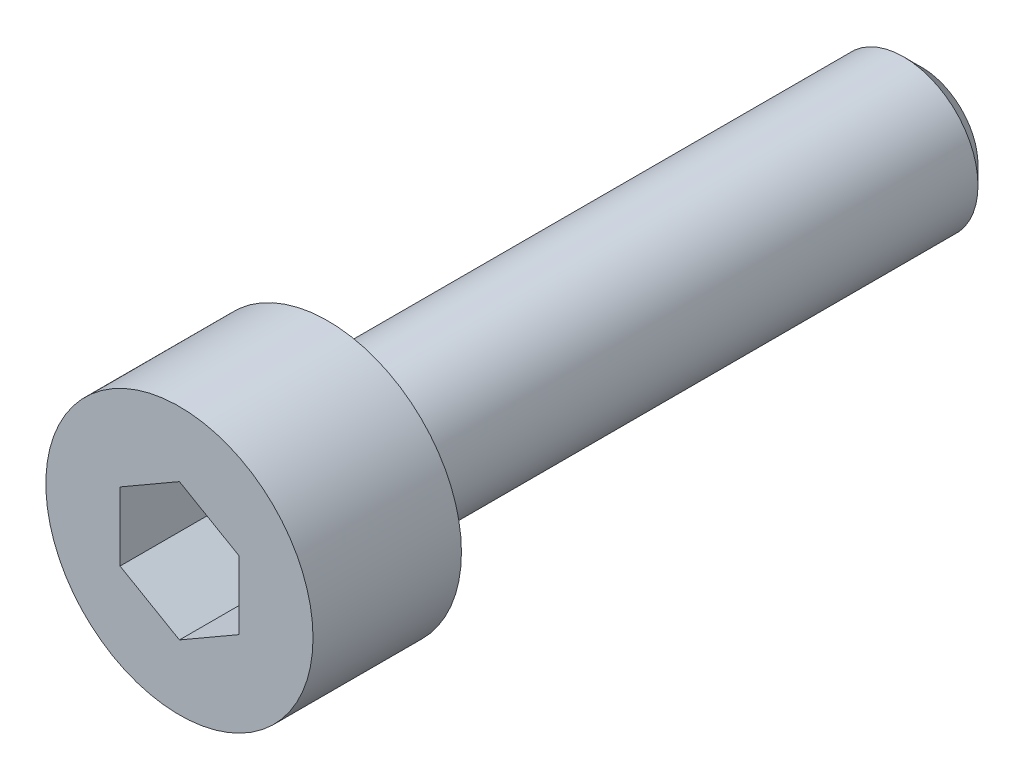
from build123d import *

# Parameters (mm, degrees)
SKETCH1_R           = 2.25
BOSS_EXTRUDE1_DEPTH = 2.5
SKETCH2_R           = 1.25
BOSS_EXTRUDE2_DEPTH = 10
CHAMFER1_SIZE       = 0.3
CUT_EXTRUDE1_DEPTH  = 2


with BuildPart() as part:
    # Sketch1 → Boss-Extrude1 (new body)
    with BuildSketch(Plane.XY):
        Circle(SKETCH1_R)
    extrude(amount=BOSS_EXTRUDE1_DEPTH)

    # Sketch2 → Boss-Extrude2 (add)
    with BuildSketch(Plane(origin=(0, 0, 0), x_dir=(-1, 0, 0), z_dir=(0, 0, -1))):
        Circle(SKETCH2_R)
    extrude(amount=BOSS_EXTRUDE2_DEPTH)

    # Chamfer1
    chamfer1_edges = [part.edges().sort_by_distance(p)[0] for p in [
        (1.25, 0, -10),
    ]]
    chamfer(chamfer1_edges, length=CHAMFER1_SIZE)

    # Sketch3 → Cut-Extrude1 (cut)
    with BuildSketch(Plane.XY.offset(2.5)):
        Polygon((0, 1.154700538), (-1, 0.577350269), (-1, -0.577350269), (0, -1.154700538), (1, -0.577350269), (1, 0.577350269), align=None)
    extrude(amount=-CUT_EXTRUDE1_DEPTH, mode=Mode.SUBTRACT)


solid = part.part
